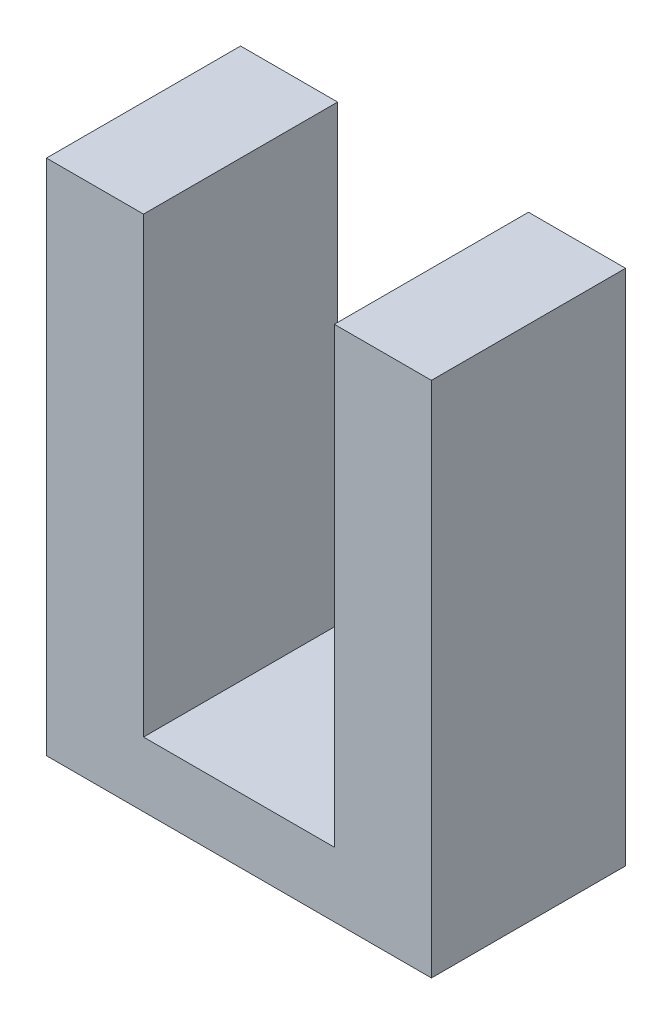
from build123d import *

# Parameters (mm, degrees)
SALIENTE_EXTRUIR1_DEPTH = 1.5


with BuildPart() as part:
    # Croquis2 → Saliente-Extruir1 (new body, symmetric)
    with BuildSketch(Plane.XY):
        Polygon((-2.975, 7), (-2.975, -1), (2.975, -1), (2.975, 7), (1.475, 7), (1.475, 0), (-1.475, 0), (-1.475, 7), align=None)
    extrude(amount=SALIENTE_EXTRUIR1_DEPTH, both=True)


solid = part.part
